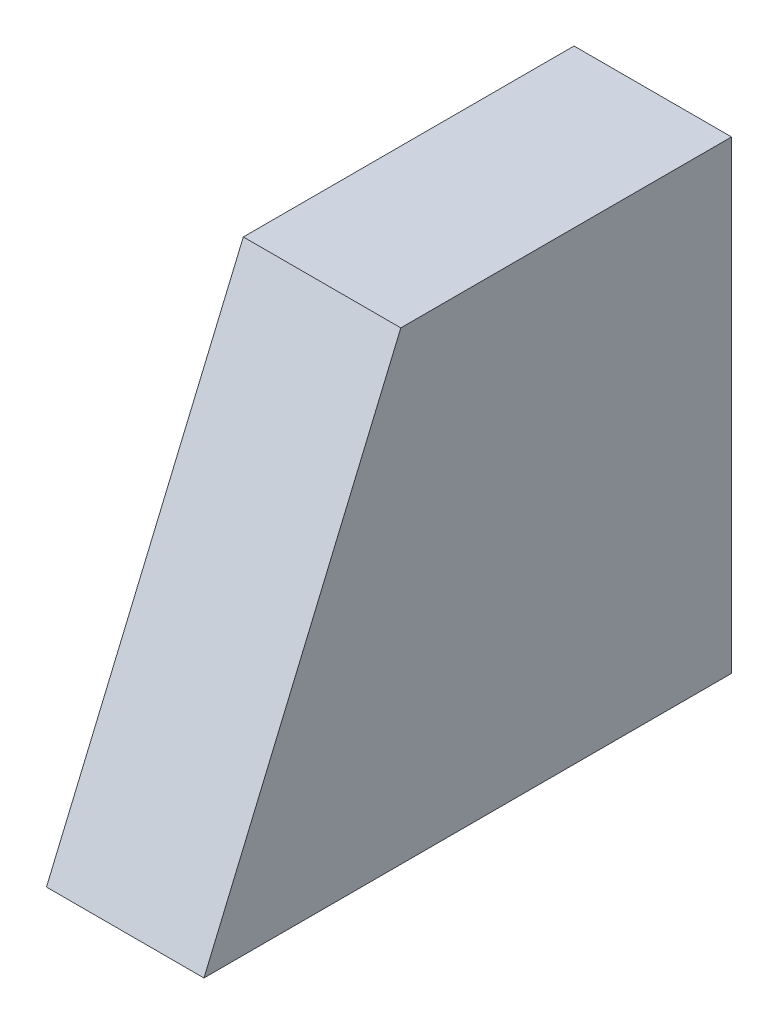
from build123d import *

# Parameters (mm, degrees)
BOSS_EXTRUDE1_DEPTH = 100


with BuildPart() as part:
    # Sketch1 → Boss-Extrude1 (new body)
    with BuildSketch(Plane(origin=(0, 0, 0), x_dir=(0, 0, -1), z_dir=(1, 0, 0))):
        Polygon((0, 0), (0, 295), (-210, 295), (-335, 0), align=None)
    extrude(amount=BOSS_EXTRUDE1_DEPTH)


solid = part.part
